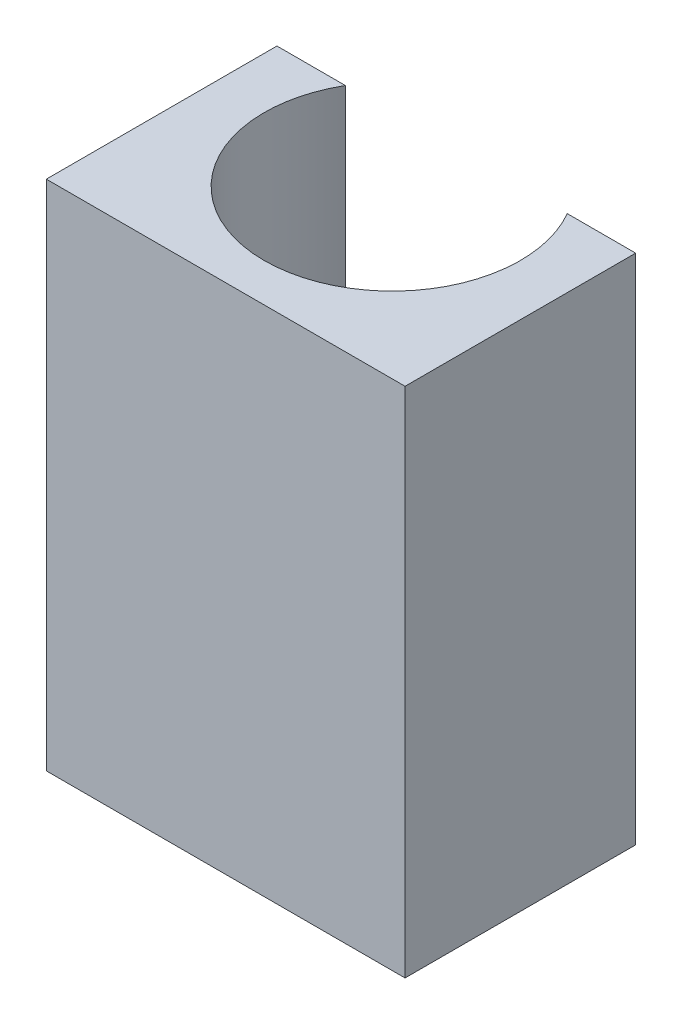
from build123d import *

# Parameters (mm, degrees)
BOSS_EXTRUDE1_DEPTH = 20


with BuildPart() as part:
    # Sketch1 → Boss-Extrude1 (new body)
    with BuildSketch(Plane(origin=(0, 0, 0), x_dir=(1, 0, 0), z_dir=(0, 1, 0))):
        with BuildLine():
            Line((-4.330127019, 4.5), (-7, 4.5))
            Line((-7, 4.5), (-7, -4.5))
            Line((-7, -4.5), (7, -4.5))
            Line((7, -4.5), (7, 4.5))
            Line((7, 4.5), (4.330127019, 4.5))
            ThreePointArc((4.330127019, 4.5), (0, -3), (-4.330127019, 4.5))
        make_face()
    extrude(amount=BOSS_EXTRUDE1_DEPTH)


solid = part.part
